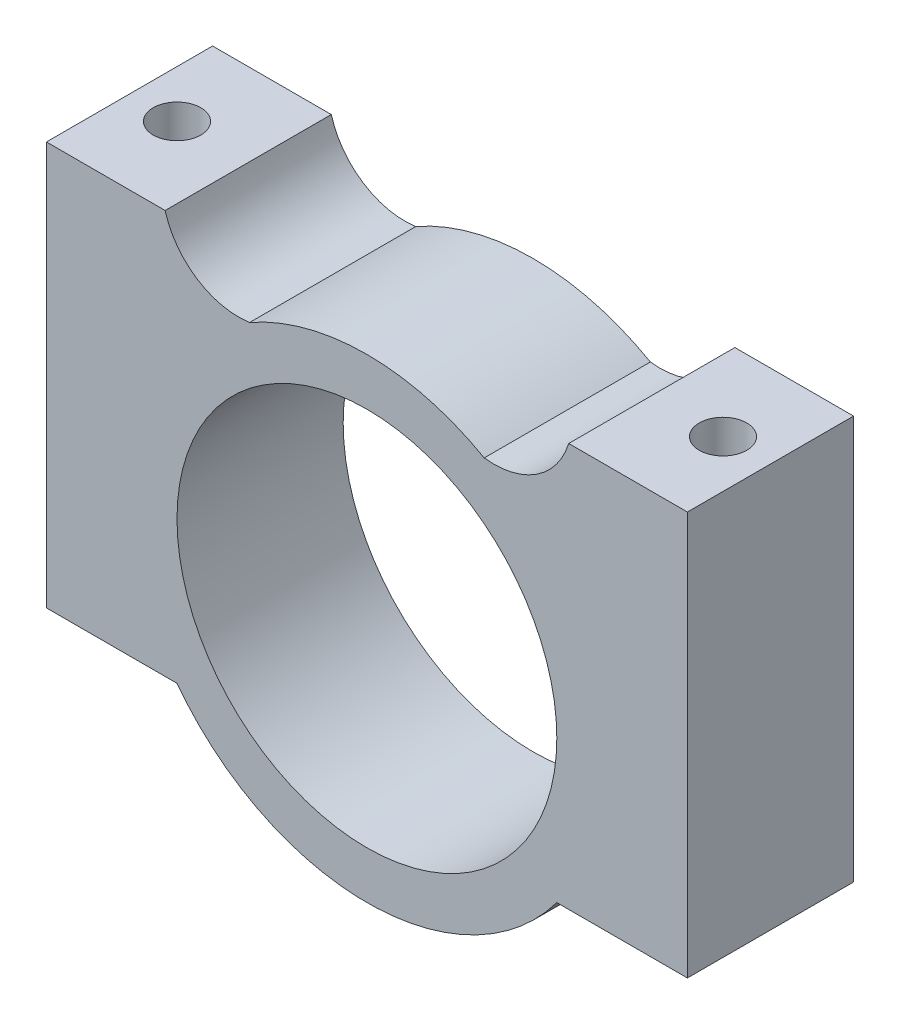
from build123d import *

# Parameters (mm, degrees)
SKETCH1_R           = 8
BOSS_EXTRUDE1_DEPTH = 7
SKETCH2_R           = 1
CUT_EXTRUDE1_DEPTH  = 22


with BuildPart() as part:
    # Sketch1 → Boss-Extrude1 (new body)
    with BuildSketch(Plane.XY):
        with BuildLine():
            Line((-13.5, 8.5), (-8.5, 8.5))
            ThreePointArc((-8.5, 8.5), (-7.155483469, 6.675741758), (-4.941082547, 6.194003868))
            ThreePointArc((-4.941082547, 6.194003868), (0, 7.5), (4.941082547, 6.194003868))
            ThreePointArc((4.941082547, 6.194003868), (7.141563471, 6.697224935), (8.5, 8.5))
            Line((8.5, 8.5), (13.5, 8.5))
            Line((13.5, 8.5), (13.5, -8.5))
            Line((13.5, -8.5), (8, -8.5))
            ThreePointArc((8, -8.5), (0, -12.5), (-8, -8.5))
            Line((-8, -8.5), (-13.5, -8.5))
            Line((-13.5, -8.5), (-13.5, 8.5))
        make_face()
        with Locations((0, -2.5)):
            Circle(SKETCH1_R, mode=Mode.SUBTRACT)
    extrude(amount=BOSS_EXTRUDE1_DEPTH)

    # Sketch2 → Cut-Extrude1 (cut, through all)
    with BuildSketch(Plane(origin=(0, 8.5, 0), x_dir=(1, 0, 0), z_dir=(0, 1, 0))):
        with Locations((-11.5, -3.5)):
            Circle(SKETCH2_R)
        with Locations((11.5, -3.5)):
            Circle(SKETCH2_R)
    extrude(amount=-CUT_EXTRUDE1_DEPTH, mode=Mode.SUBTRACT)


solid = part.part
